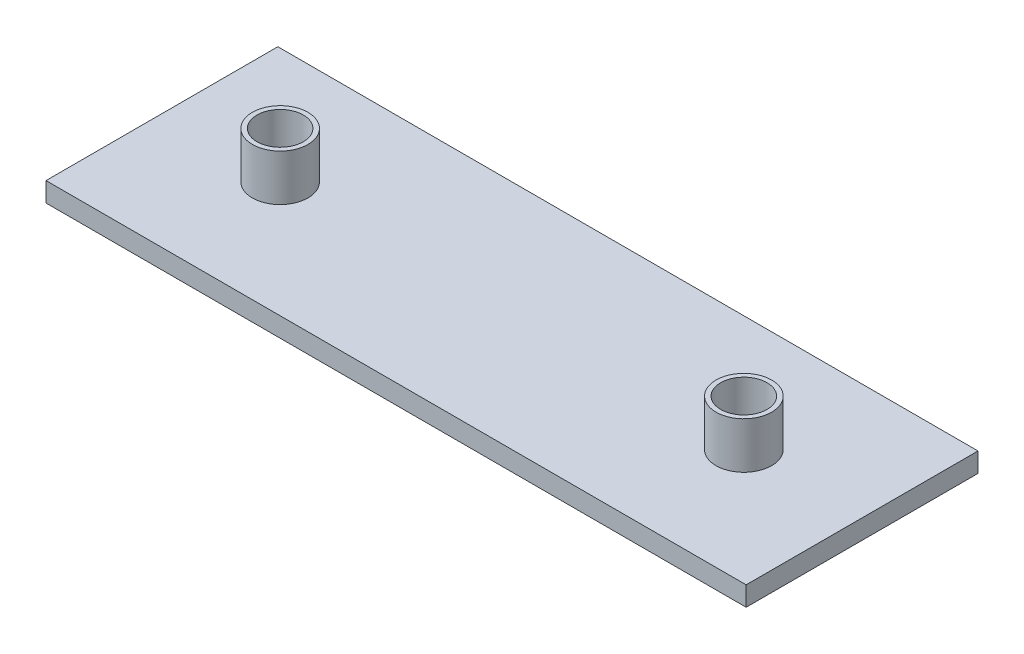
from build123d import *

# Parameters (mm, degrees)
SKETCH1_W               = 75.5
SKETCH1_H               = 25
BOSS_EXTRUDE1_DEPTH     = 2.1
CUT_EXTRUDE1_DEPTH      = 0.2
CUT_EXTRUDE1_DEPTH_BACK = 0.2
SKETCH4_R               = 3
SKETCH4_R_2             = 2.5
BOSS_EXTRUDE2_DEPTH     = 5
SKETCH5_R               = 2.5
CUT_EXTRUDE5_DEPTH      = 0.5


with BuildPart() as part:
    # Sketch1 → Boss-Extrude1 (new body)
    with BuildSketch(Plane(origin=(0, 0, 0), x_dir=(1, 0, 0), z_dir=(0, 1, 0))):
        with Locations((-9.096373467, 8.083487785)):
            Rectangle(SKETCH1_W, SKETCH1_H)
    extrude(amount=BOSS_EXTRUDE1_DEPTH)

    # Sketch3 → Cut-Extrude1 (cut, two sides)
    with BuildSketch(Plane(origin=(0, 1.05, 0), x_dir=(-1, 0, 0), z_dir=(0, -1, 0))) as cut_extrude1_sk:
        with BuildLine():
            Line((34.096373467, 5.583487785), (-15.903626533, 5.583487785))
            ThreePointArc((-15.903626533, 5.583487785), (-18.403626533, 8.083487785), (-15.903626533, 10.583487785))
            Line((-15.903626533, 10.583487785), (34.096373467, 10.583487785))
            ThreePointArc((34.096373467, 10.583487785), (36.596373467, 8.083487785), (34.096373467, 5.583487785))
        make_face()
    extrude(amount=CUT_EXTRUDE1_DEPTH, mode=Mode.SUBTRACT)
    extrude(cut_extrude1_sk.sketch, amount=-CUT_EXTRUDE1_DEPTH_BACK, mode=Mode.SUBTRACT)

    # Sketch4 → Boss-Extrude2 (add)
    with BuildSketch(Plane(origin=(0, 2.1, 0), x_dir=(1, 0, 0), z_dir=(0, 1, 0))):
        with Locations((-34.096373467, 8.083487785)):
            Circle(SKETCH4_R)
        with Locations((-34.096373467, 8.083487785)):
            Circle(SKETCH4_R_2, mode=Mode.SUBTRACT)
        with Locations((15.903626533, 8.083487785)):
            Circle(SKETCH4_R)
        with Locations((15.903626533, 8.083487785)):
            Circle(SKETCH4_R_2, mode=Mode.SUBTRACT)
    extrude(amount=BOSS_EXTRUDE2_DEPTH)

    # Sketch5 → Cut-Extrude5 (cut)
    with BuildSketch(Plane.XZ.offset(-1.25)):
        with Locations((-34.096373467, -8.083487785)):
            Circle(SKETCH5_R)
        with Locations((15.903626533, -8.083487785)):
            Circle(SKETCH5_R)
    extrude(amount=-CUT_EXTRUDE5_DEPTH, mode=Mode.SUBTRACT)


solid = part.part
